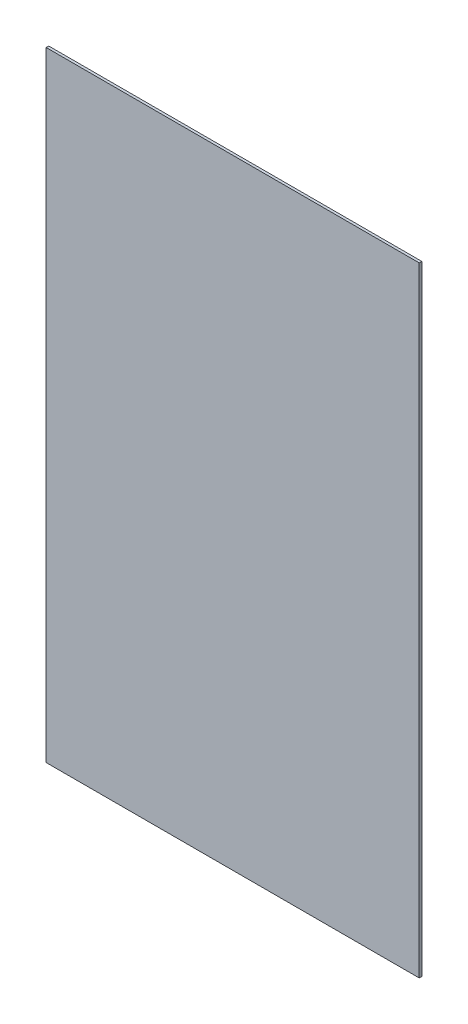
from build123d import *

# Parameters (mm, degrees)
SKETCH1_W           = 457.2
SKETCH1_H           = 758.9266
BOSS_EXTRUDE1_DEPTH = 3.175


with BuildPart() as part:
    # Sketch1 → Boss-Extrude1 (new body)
    with BuildSketch(Plane.XY):
        with Locations((228.6, 379.4633)):
            Rectangle(SKETCH1_W, SKETCH1_H)
    extrude(amount=BOSS_EXTRUDE1_DEPTH)


solid = part.part
